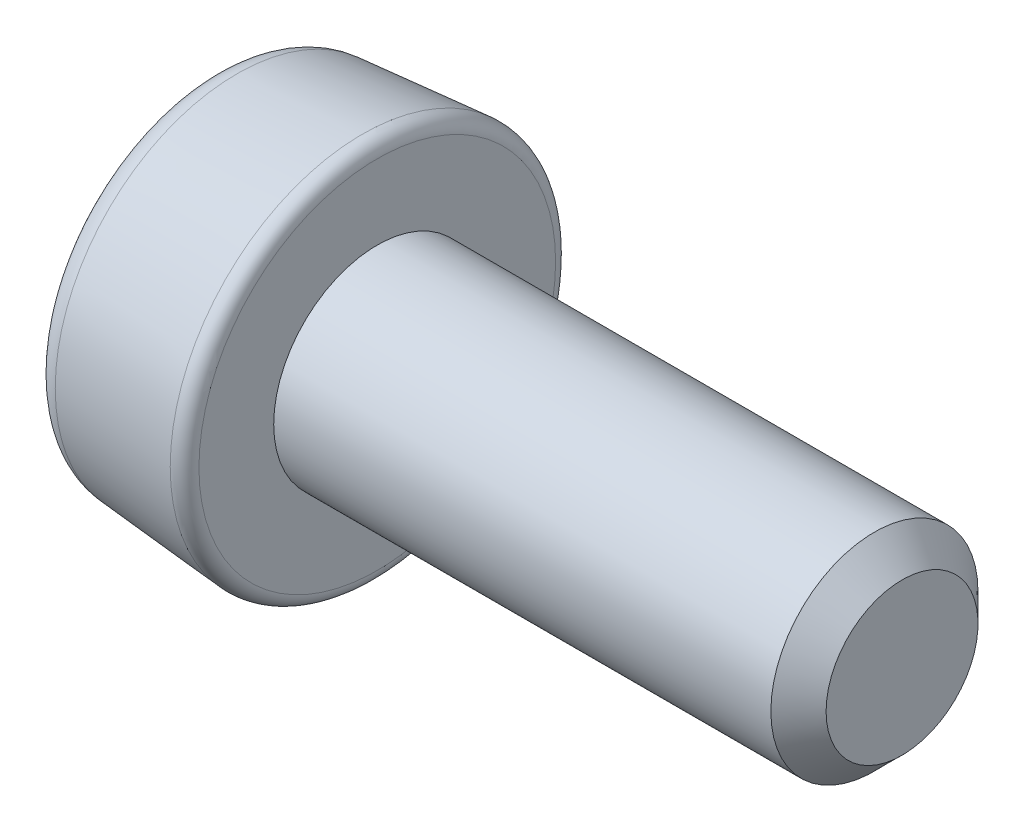
from build123d import *

# Parameters (mm, degrees)
ESQUISSE2_W                  = 0.3
ESQUISSE2_H                  = 0.7
EXTRUSION1_DEPTH             = 0.8
R_P_TITION_CIRCULAIRE1_COUNT = 4
CHANFREIN1_SIZE              = 0.2


with BuildPart() as part:
    # Esquisse1 → Révolution1 (revolve)
    with BuildSketch(Plane.XY, mode=Mode.PRIVATE) as r_volution1_sk:
        with BuildLine():
            Line((3.8, 0), (3.8, 0.55))
            Line((3.8, 0.55), (3.6, 0.75))
            Line((3.6, 0.75), (0, 0.75))
            Line((0, 0.75), (0, 1.291320045))
            ThreePointArc((0, 1.291320045), (-0.032289051, 1.364908274), (-0.108304548, 1.390974621))
            Line((-0.108304548, 1.390974621), (-1.016609096, 1.315282575))
            ThreePointArc((-1.016609096, 1.315282575), (-1.147176457, 1.251395321), (-1.2, 1.115973424))
            Line((-1.2, 1.115973424), (-1.2, 0))
            Line((-1.2, 0), (3.8, 0))
        make_face()
    revolve(r_volution1_sk.sketch.rotate(Axis((-2.783918663, 0, 0), (1, 0, 0)), 90), axis=Axis((-2.783918663, 0, 0), (1, 0, 0)))  # turned: the seam where the file's is

    # Esquisse2 → Extrusion1 (cut)
    with BuildSketch(Plane.ZY.offset(1.2)):
        with Locations((0, 0.35)):
            Rectangle(ESQUISSE2_W, ESQUISSE2_H)
    extrusion1 = extrude(amount=-EXTRUSION1_DEPTH, mode=Mode.SUBTRACT)

    # Répétition circulaire1: Extrusion1 ×4 about axis
    r_p_tition_circulaire1_axis = Axis((0, 0, 0), (1, 0, 0))
    for i in range(1, R_P_TITION_CIRCULAIRE1_COUNT):
        add(extrusion1.rotate(r_p_tition_circulaire1_axis, i * 360 / R_P_TITION_CIRCULAIRE1_COUNT), mode=Mode.SUBTRACT)

    # Chanfrein1
    chanfrein1_edges = [part.edges().sort_by_distance(p)[0] for p in [
        (-0.8, 0.15, -0.15),
        (-0.8, 0.15, 0.15),
        (-0.8, -0.15, -0.15),
        (-0.8, -0.15, 0.15),
    ]]
    chamfer(chanfrein1_edges, length=CHANFREIN1_SIZE)


solid = part.part
